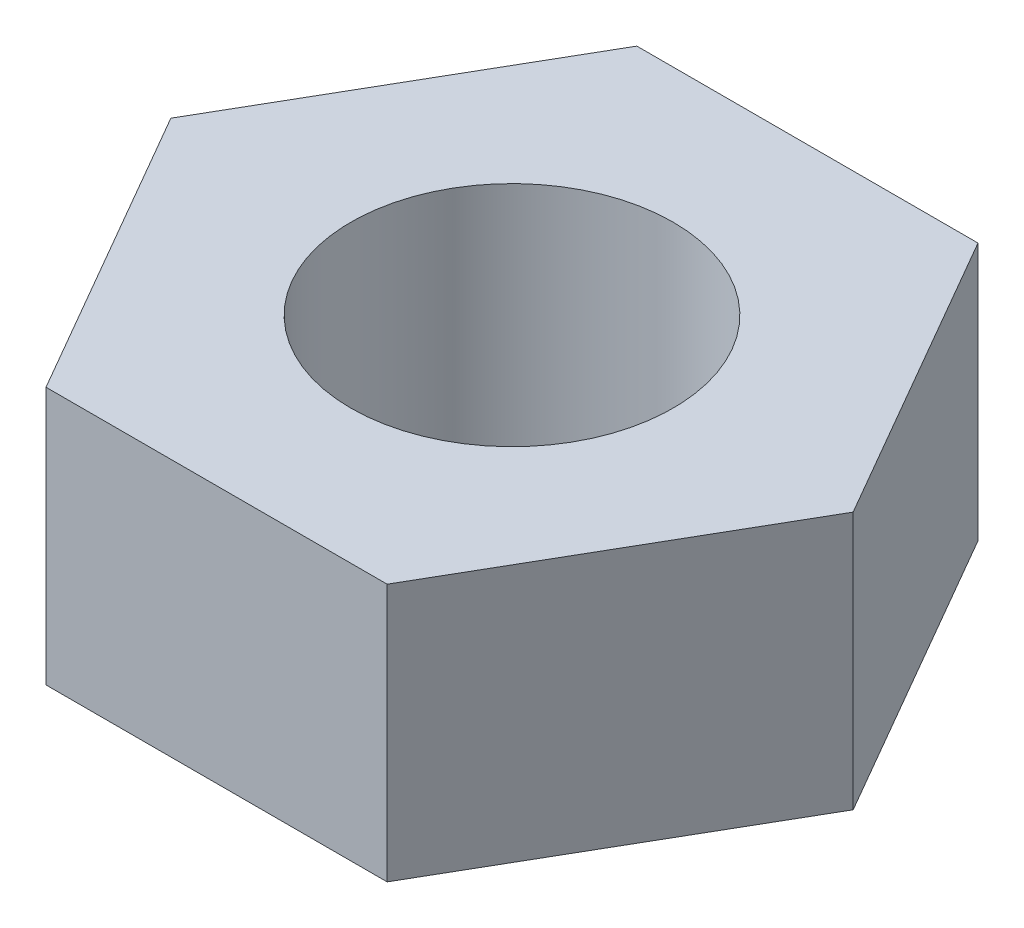
from build123d import *

# Parameters (mm, degrees)
SKETCH1_R      = 1.5
EXTRUDE1_DEPTH = 2.4


with BuildPart() as part:
    # Sketch1 → Extrude1 (new body)
    with BuildSketch(Plane(origin=(0, 0, 0), x_dir=(1, 0, 0), z_dir=(0, 1, 0))):
        Polygon((1.58771324, -2.75), (3.175426481, 0), (1.58771324, 2.75), (-1.58771324, 2.75), (-3.175426481, 0), (-1.58771324, -2.75), align=None)
        with Locations(Location((0, 0, 0), (0, 0, 270))):  # turned: the seam where the file's is
            Circle(SKETCH1_R, mode=Mode.SUBTRACT)
    extrude(amount=EXTRUDE1_DEPTH)


solid = part.part
